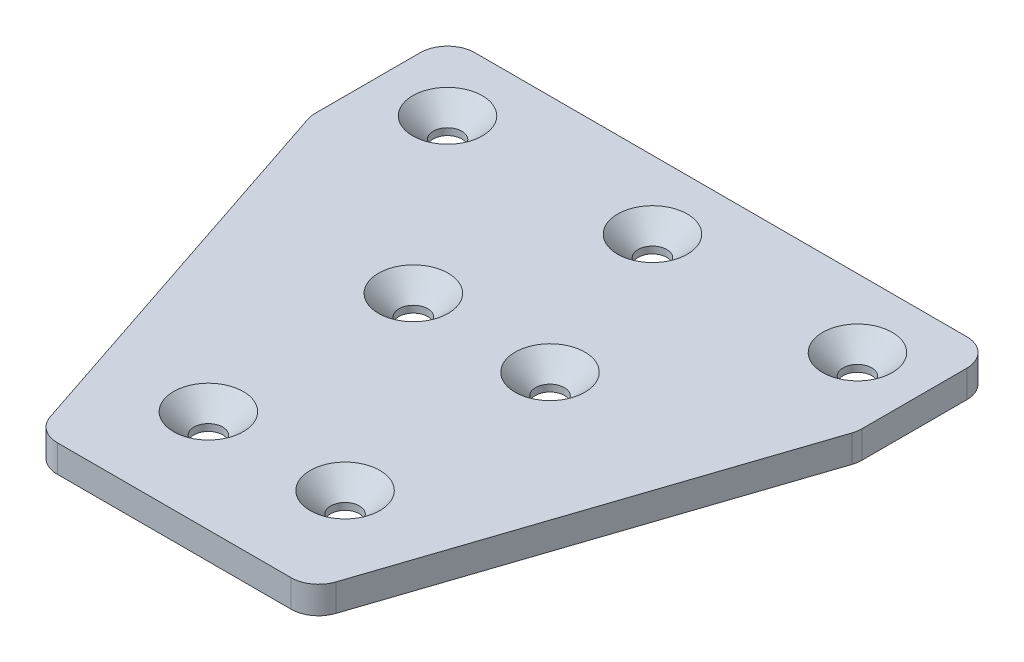
from build123d import *

# Parameters (mm, degrees)
SKETCH1_W           = 40
SKETCH1_H           = 60
SKETCH1_R           = 2.1
SKETCH1_W_2         = 80
SKETCH1_H_2         = 20
BOSS_EXTRUDE1_DEPTH = 4
CHAMFER1_SIZE       = 3
FILLET1_R           = 4


with BuildPart() as part:
    # Sketch1 → Boss-Extrude1 (new body)
    with BuildSketch(Plane(origin=(0, 0, 0), x_dir=(1, 0, 0), z_dir=(0, 1, 0))):
        with Locations((0, -40)):
            Rectangle(SKETCH1_W, SKETCH1_H)
        with Locations((-10, -55)):
            Circle(SKETCH1_R, mode=Mode.SUBTRACT)
        with Locations((10, -55)):
            Circle(SKETCH1_R, mode=Mode.SUBTRACT)
        with Locations((-10, -25)):
            Circle(SKETCH1_R, mode=Mode.SUBTRACT)
        with Locations((10, -25)):
            Circle(SKETCH1_R, mode=Mode.SUBTRACT)
        Polygon((-20, -10), (-40, -10), (-20, -70), align=None)
        Polygon((40, -10), (20, -10), (20, -70), align=None)
        Rectangle(SKETCH1_W_2, SKETCH1_H_2)
        Circle(SKETCH1_R, mode=Mode.SUBTRACT)
        with Locations((30, 0)):
            Circle(SKETCH1_R, mode=Mode.SUBTRACT)
        with Locations((-30, 0)):
            Circle(SKETCH1_R, mode=Mode.SUBTRACT)
    extrude(amount=BOSS_EXTRUDE1_DEPTH)

    # Chamfer1
    chamfer1_edges = [part.edges().sort_by_distance(p)[0] for p in [
        (-12.1, 4, 55),
        (7.9, 4, 55),
        (7.9, 4, 25),
        (-12.1, 4, 25),
        (-2.1, 4, 0),
        (27.9, 4, 0),
        (-32.1, 4, 0),
    ]]
    chamfer(chamfer1_edges, length=CHAMFER1_SIZE)

    # Fillet1
    fillet1_edges = [part.edges().sort_by_distance(p)[0] for p in [
        (20, 2, 70),
        (-20, 2, 70),
        (-40, 2, 10),
        (-40, 2, -10),
        (40, 2, -10),
        (40, 2, 10),
    ]]
    fillet(fillet1_edges, radius=FILLET1_R)


solid = part.part
